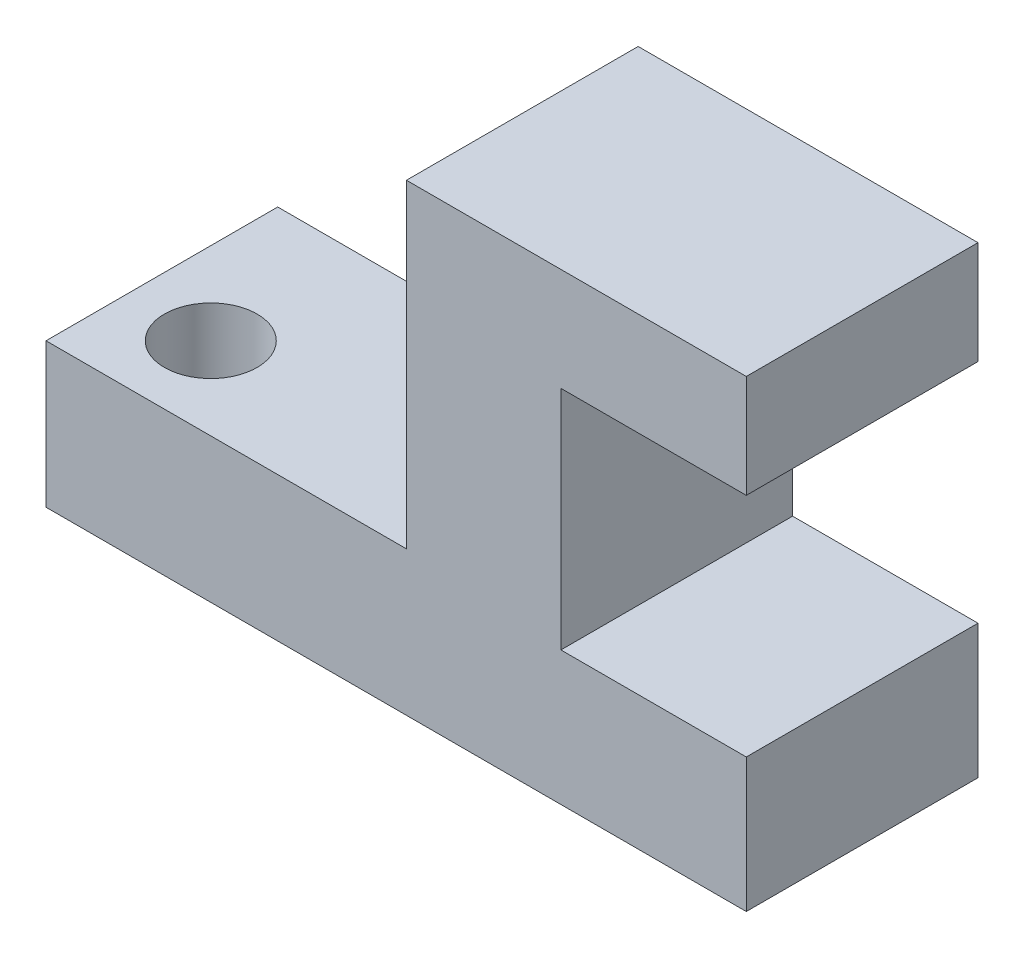
from build123d import *

# Parameters (mm, degrees)
BOSS_EXTRUDE1_DEPTH = 4.5
SKETCH2_R           = 0.9
CUT_EXTRUDE1_DEPTH  = 10


with BuildPart() as part:
    # Sketch1 → Boss-Extrude1 (new body)
    with BuildSketch(Plane.XY):
        Polygon((0, 0), (-13.6, 0), (-13.6, 2.8), (-6.6, 2.8), (-6.6, 9), (0, 9), (0, 7), (-3.6, 7), (-3.6, 2.6), (0, 2.6), align=None)
    extrude(amount=BOSS_EXTRUDE1_DEPTH)

    # Sketch2 → Cut-Extrude1 (cut)
    with BuildSketch(Plane(origin=(0, 2.8, 0), x_dir=(1, 0, 0), z_dir=(0, 1, 0))):
        with Locations((-8.2, -1.6)):
            Circle(SKETCH2_R)
        with Locations((-12, -2.9)):
            Circle(SKETCH2_R)
    extrude(amount=-CUT_EXTRUDE1_DEPTH, mode=Mode.SUBTRACT)


solid = part.part
